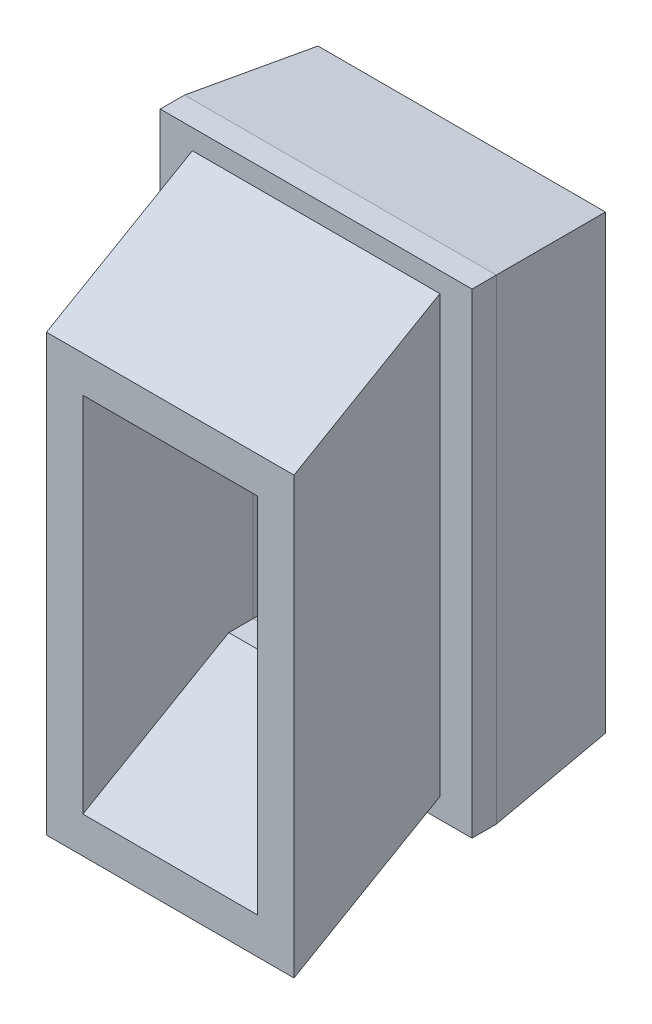
from build123d import *

# Parameters (mm, degrees)
SKETCH3_W           = 25.7
SKETCH3_H           = 39.2
SKETCH3_W_2         = 14.4
SKETCH3_H_2         = 29.9
BOSS_EXTRUDE2_DEPTH = 12
CHAMFER1_SIZE       = 1
CHAMFER1_SIZE2      = 10
SKETCH4_W           = 20.4
SKETCH4_H           = 35.9
SKETCH4_W_2         = 14.4
SKETCH4_H_2         = 29.9


with BuildPart() as part:
    # Sketch3 → Boss-Extrude2 (new body)
    with BuildSketch(Plane.XY):
        with Locations((12.85, 19.6)):
            Rectangle(SKETCH3_W, SKETCH3_H)
        with Locations((12.85, 19.6)):
            Rectangle(SKETCH3_W_2, SKETCH3_H_2, mode=Mode.SUBTRACT)
    extrude(amount=BOSS_EXTRUDE2_DEPTH)

    # Chamfer1
    chamfer1_edges = [part.edges().sort_by_distance(p)[0] for p in [
        (5.65, 19.6, 0),
        (12.85, 4.65, 0),
        (20.05, 19.6, 0),
        (12.85, 34.55, 0),
        (12.85, 39.2, 0),
        (25.7, 19.6, 0),
        (12.85, 0, 0),
        (0, 19.6, 0),
    ]]
    chamfer1_side = [part.faces().sort_by_distance(p)[0] for p in [
        (12.85, 0.468735533, 0),
    ]]
    chamfer(chamfer1_edges, length=CHAMFER1_SIZE, length2=CHAMFER1_SIZE2, reference=chamfer1_side[0])

    # Sweep1: sweep along a path in Sketch6
    with BuildLine(Plane.ZY.offset(-12.85)) as sweep1_path:
        Line((12, 1.65), (24.024266767, -5.292213655))
    # Sketch4 → Sweep1 (sweep)
    with BuildSketch(Plane.XY.offset(12)):
        with Locations((12.85, 19.6)):
            Rectangle(SKETCH4_W, SKETCH4_H)
        with Locations((12.85, 19.6)):
            Rectangle(SKETCH4_W_2, SKETCH4_H_2, mode=Mode.SUBTRACT)
    sweep(path=sweep1_path.line)


solid = part.part
